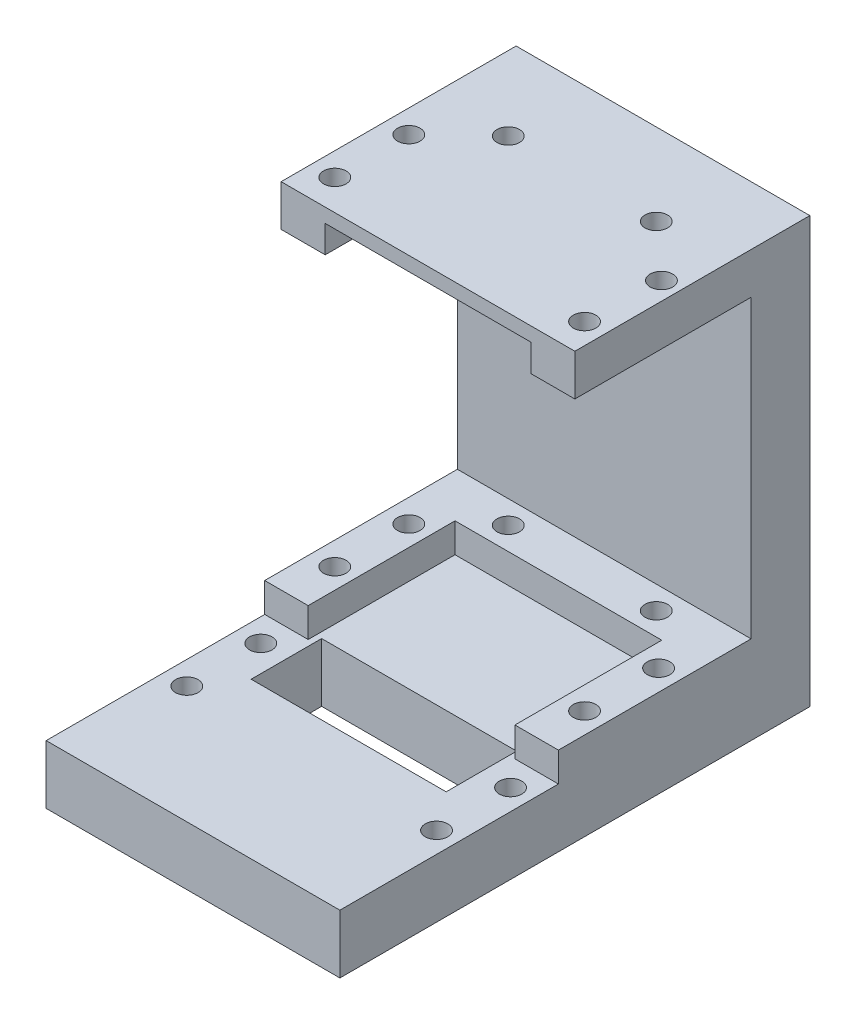
from build123d import *

# Parameters (mm, degrees)
SKETCH1_W                 = 31.75
SKETCH1_H                 = 50.8
BOSS_EXTRUDE1_DEPTH       = 45.974
CUT_EXTRUDE1_DEPTH        = 32.75
SKETCH3_W                 = 22.352
SKETCH3_H                 = 15.875
CUT_EXTRUDE2_DEPTH        = 3.175
SKETCH4_W                 = 31.75
SKETCH4_H                 = 25.4
CUT_EXTRUDE3_DEPTH        = 4.4704
CUT_EXTRUDE4_START        = -1.524
SKETCH5_W                 = 22.225
SKETCH5_H                 = 12.7
CUT_EXTRUDE4_DEPTH        = 2.9464
F_2_CLEARANCE_HOLE1_D     = 2.4384
F_2_CLEARANCE_HOLE1_DEPTH = 9.525
F_2_CLEARANCE_HOLE2_D     = 2.4384
F_2_CLEARANCE_HOLE2_DEPTH = 4.4704
SKETCH10_W                = 21.082
SKETCH10_H                = 7.62
CUT_EXTRUDE5_DEPTH        = 6.35
F_2_CLEARANCE_HOLE3_D     = 2.4384


with BuildPart() as part:
    # Sketch1 → Boss-Extrude1 (new body)
    with BuildSketch(Plane(origin=(0, 0, 0), x_dir=(1, 0, 0), z_dir=(0, 1, 0))):
        Rectangle(SKETCH1_W, SKETCH1_H)
    extrude(amount=BOSS_EXTRUDE1_DEPTH)

    # Sketch2 → Cut-Extrude1 (cut, through all)
    with BuildSketch(Plane.ZY.offset(15.875)):
        Polygon((1.778, 6.35), (25.4, 6.35), (25.4, 41.5036), (-19.05, 41.5036), (-19.05, 9.525), (1.778, 9.525), align=None)
    extrude(amount=-CUT_EXTRUDE1_DEPTH, mode=Mode.SUBTRACT)

    # Sketch3 → Cut-Extrude2 (cut)
    with BuildSketch(Plane(origin=(0, 9.525, 0), x_dir=(1, 0, 0), z_dir=(0, 1, 0))):
        with Locations((0, 6.1595)):
            Rectangle(SKETCH3_W, SKETCH3_H)
    extrude(amount=-CUT_EXTRUDE2_DEPTH, mode=Mode.SUBTRACT)

    # Sketch4 → Cut-Extrude3 (cut)
    with BuildSketch(Plane(origin=(0, 45.974, 0), x_dir=(1, 0, 0), z_dir=(0, 1, 0))):
        with Locations((0, -12.7)):
            Rectangle(SKETCH4_W, SKETCH4_H)
    extrude(amount=-CUT_EXTRUDE3_DEPTH, mode=Mode.SUBTRACT)

    # Sketch5 → Cut-Extrude4 (cut)
    with BuildSketch(Plane(origin=(0, 45.974, 0), x_dir=(1, 0, 0), z_dir=(0, 1, 0)).offset(CUT_EXTRUDE4_START)):
        with Locations((0, 6.35)):
            Rectangle(SKETCH5_W, SKETCH5_H)
    extrude(amount=-CUT_EXTRUDE4_DEPTH, mode=Mode.SUBTRACT)

    # #2 Clearance Hole1
    with Locations(Plane(origin=(0, 9.525, 0), x_dir=(1, 0, 0), z_dir=(0, 1, 0))):
        with Locations((-13.375, 11.3), (-13.375, 3.3), (-7.875, 16.55), (8.125, 16.55), (13.625, 3.3), (13.625, 11.3)):
            Hole(F_2_CLEARANCE_HOLE1_D / 2, depth=F_2_CLEARANCE_HOLE1_DEPTH)

    # #2 Clearance Hole2
    with Locations(Plane(origin=(0, 41.5036, 0), x_dir=(-1, 0, 0), z_dir=(0, -1, 0))):
        with Locations((13.375, 11.3), (7.875, 16.55), (-8.125, 16.55), (-13.932840587, 11.3), (-13.625, 3.3), (13.375, 3.3)):
            Hole(F_2_CLEARANCE_HOLE2_D / 2, depth=F_2_CLEARANCE_HOLE2_DEPTH)

    # Sketch10 → Cut-Extrude5 (cut)
    with BuildSketch(Plane(origin=(0, 6.35, 0), x_dir=(1, 0, 0), z_dir=(0, 1, 0))):
        with Locations((0, -4.767798325)):
            Rectangle(SKETCH10_W, SKETCH10_H)
    extrude(amount=-CUT_EXTRUDE5_DEPTH, mode=Mode.SUBTRACT)

    # #2 Clearance Hole3 (through all)
    with Locations(Plane(origin=(0, 6.35, 0), x_dir=(1, 0, 0), z_dir=(0, 1, 0))):
        with Locations((-13.375, -4.7), (-13.375, -12.7), (13.625, -12.7), (13.625, -4.7)):
            Hole(F_2_CLEARANCE_HOLE3_D / 2)


solid = part.part
